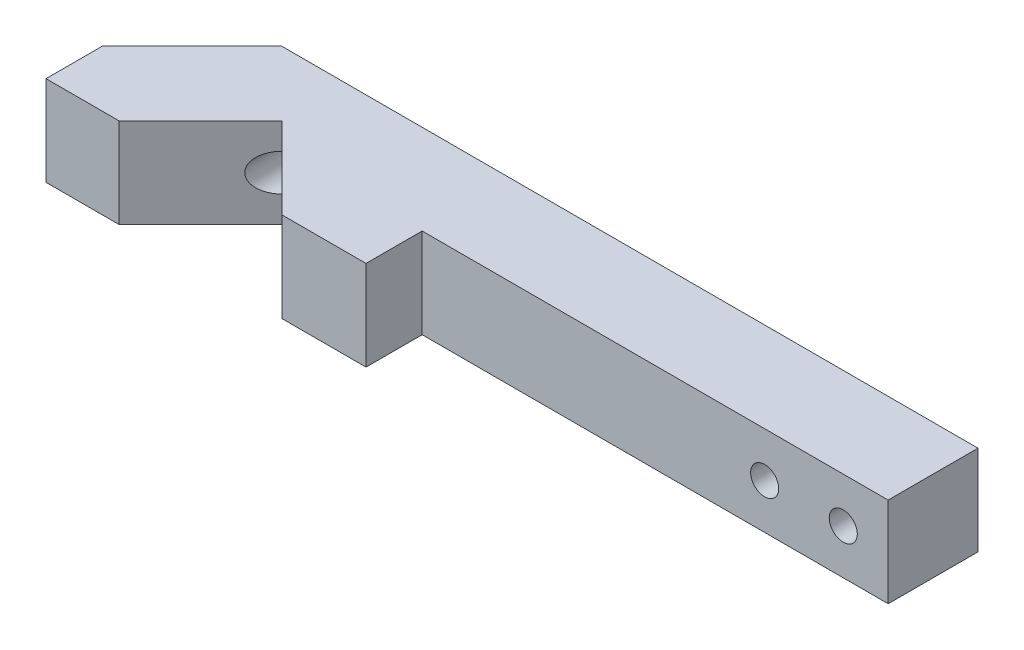
from build123d import *

# Parameters (mm, degrees)
BOSS_EXTRUDE2_DEPTH   = 8
M4_TAPPED_HOLE1_D     = 3.3
M4_TAPPED_HOLE1_DEPTH = 11.5
M4_TAPPED_HOLE1_TIP   = 0.991420021
M3_TAPPED_HOLE1_D     = 2.5
M3_TAPPED_HOLE1_DEPTH = 8.5
M3_TAPPED_HOLE1_TIP   = 0.751075774


with BuildPart() as part:
    # Sketch1 → Boss-Extrude2 (new body)
    with BuildSketch(Plane(origin=(0, 0, 0), x_dir=(1, 0, 0), z_dir=(0, 1, 0))):
        Polygon((-35, -4), (-27, 4), (35, 4), (35, -4), (-6.5, -4), (-6.5, -9), (-14, -9), (-21.25, -1.75), (-28.5, -9), (-35, -9), align=None)
    extrude(amount=BOSS_EXTRUDE2_DEPTH)

    # M4 Tapped Hole1
    with Locations(Plane(origin=(0, 0, -4), x_dir=(-1, 0, 0), z_dir=(0, 0, -1))):
        with Locations((21.25, 4)):
            Hole(M4_TAPPED_HOLE1_D / 2, depth=M4_TAPPED_HOLE1_DEPTH)
            with Locations((0, 0, -(M4_TAPPED_HOLE1_DEPTH + M4_TAPPED_HOLE1_TIP / 2))):  # 118° drill point
                Cone(0, M4_TAPPED_HOLE1_D / 2, M4_TAPPED_HOLE1_TIP, mode=Mode.SUBTRACT)

    # M3 Tapped Hole1
    with Locations(Plane(origin=(0, 0, -4), x_dir=(-1, 0, 0), z_dir=(0, 0, -1))):
        with Locations((-31, 4), (-24, 4)):
            Hole(M3_TAPPED_HOLE1_D / 2, depth=M3_TAPPED_HOLE1_DEPTH)
            with Locations((0, 0, -(M3_TAPPED_HOLE1_DEPTH + M3_TAPPED_HOLE1_TIP / 2))):  # 118° drill point
                Cone(0, M3_TAPPED_HOLE1_D / 2, M3_TAPPED_HOLE1_TIP, mode=Mode.SUBTRACT)


solid = part.part
